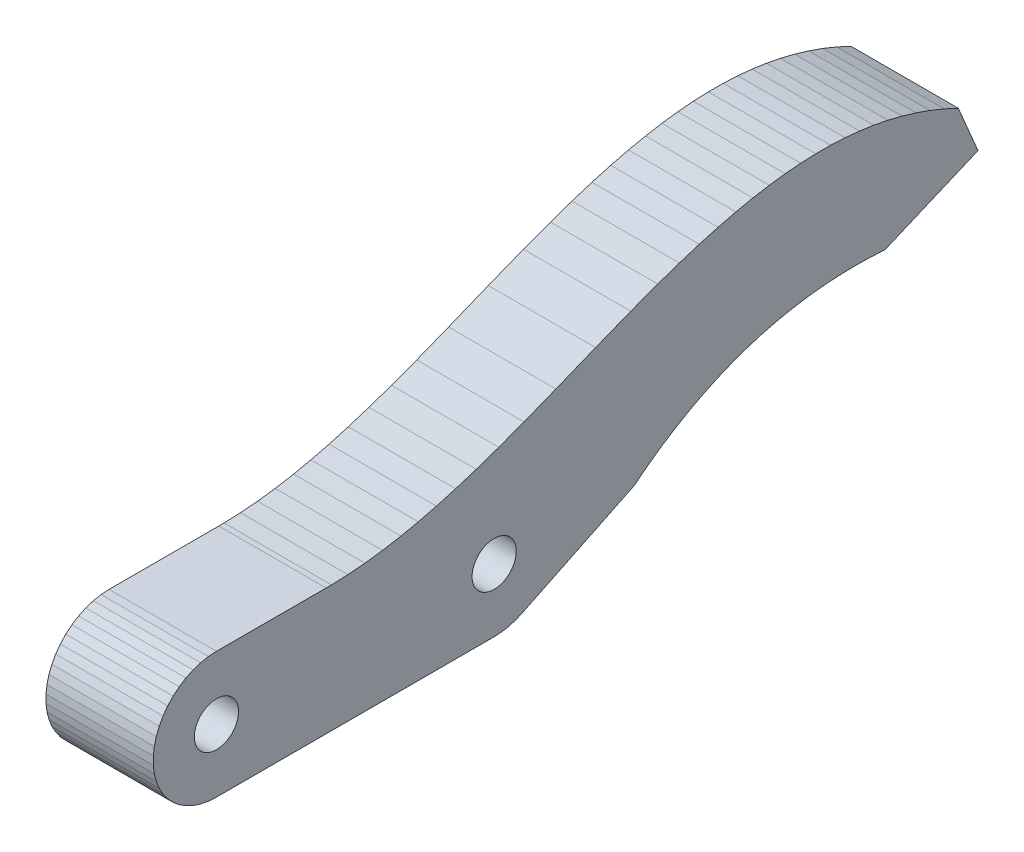
from build123d import *

# Parameters (mm, degrees)
SKETCH1_R           = 1.749997696
SKETCH1_R_2         = 1.749993894
BOSS_EXTRUDE1_DEPTH = 8.500000462


with BuildPart() as part:
    # Sketch1 → Boss-Extrude1 (new body)
    with BuildSketch(Plane(origin=(0, 0, 0), x_dir=(0, -1, 0), z_dir=(-1, 0, 0))):
        Polygon((-0.127148596, 37.193398923), (-0.031888841, 37.750009447), (0, 38.313798606), (0, 60.313809663), (-0.03942649, 60.940481722), (-0.1570842, 61.557259411), (-0.351117604, 62.154430896), (-0.618466584, 62.722578645), (-0.954915013, 63.252732158), (-1.355157001, 63.736543059), (-1.812880044, 64.166367054), (-2.3208661, 64.535446465), (-2.87110405, 64.837940037), (-3.454915015, 65.06908685), (-4.063094035, 65.225243568), (-4.686047789, 65.303951502), (-5.313951988, 65.303951502), (-5.936907139, 65.225243568), (-6.545084994, 65.06908685), (-7.128897123, 64.837940037), (-7.679134142, 64.535446465), (-8.187118918, 64.166367054), (-8.644842543, 63.736543059), (-9.045084938, 63.252732158), (-9.3815336, 62.722578645), (-9.648882784, 62.154430896), (-9.842916392, 61.557259411), (-9.960573167, 60.940481722), (-9.999999776, 60.313809663), (-9.999999776, 51.61882937), (-10.003159754, 51.202278584), (-10.053309612, 49.896221608), (-10.166640393, 48.549070954), (-10.346939787, 47.150671482), (-10.599040426, 45.690581203), (-10.890450329, 44.321350753), (-11.248489842, 42.885411531), (-11.680469848, 41.3646698), (-12.197230011, 39.732418954), (-12.815520167, 37.947189063), (-13.558279723, 35.951770842), (-14.55048006, 33.42717886), (-15.819819644, 30.277069658), (-16.917720437, 27.492690831), (-17.711920664, 25.357909501), (-18.301250413, 23.649940267), (-18.799910322, 22.069010884), (-19.219560549, 20.58403939), (-19.567960873, 19.174400717), (-19.850589335, 17.825430259), (-20.071450621, 16.526099294), (-20.233500749, 15.267790295), (-20.338920876, 14.043499716), (-20.389260724, 12.84740027), (-20.385539159, 11.674479581), (-20.328279585, 10.52037999), (-20.217610523, 9.381227195), (-20.053209737, 8.253508247), (-19.83438991, 7.134027779), (-19.560100511, 6.019853055), (-19.228890538, 4.908256233), (-18.838969991, 3.796692938), (-18.388209864, 2.682805061), (-17.872419208, 1.56083703), (-14.189518528, -5.9e-07), (-11.067840271, 7.365807891), (-11.129870079, 8.45041126), (-11.15438994, 9.76248458), (-11.122629978, 11.049759574), (-11.035439558, 12.313780375), (-10.893439874, 13.556060381), (-10.697020218, 14.778049663), (-10.446329601, 15.981180593), (-10.141259991, 17.16681011), (-9.781503119, 18.3362104), (-9.366483428, 19.490620121), (-8.89539998, 20.6311699), (-8.367221802, 21.758910269), (-7.780684158, 22.874809802), (-7.134305779, 23.979740217), (-6.42638607, 25.074450299), (-5.655040033, 26.159580797), (-4.82408423, 27.228390798), (-0.502127572, 36.129970104), (-0.284564187, 36.651078612), align=None)
        with Locations((-5.001175624, 60.307227597)):
            Circle(SKETCH1_R, mode=Mode.SUBTRACT)
        with Locations((-5.000006282, 38.313804534)):
            Circle(SKETCH1_R_2, mode=Mode.SUBTRACT)
    extrude(amount=-BOSS_EXTRUDE1_DEPTH)


solid = part.part
